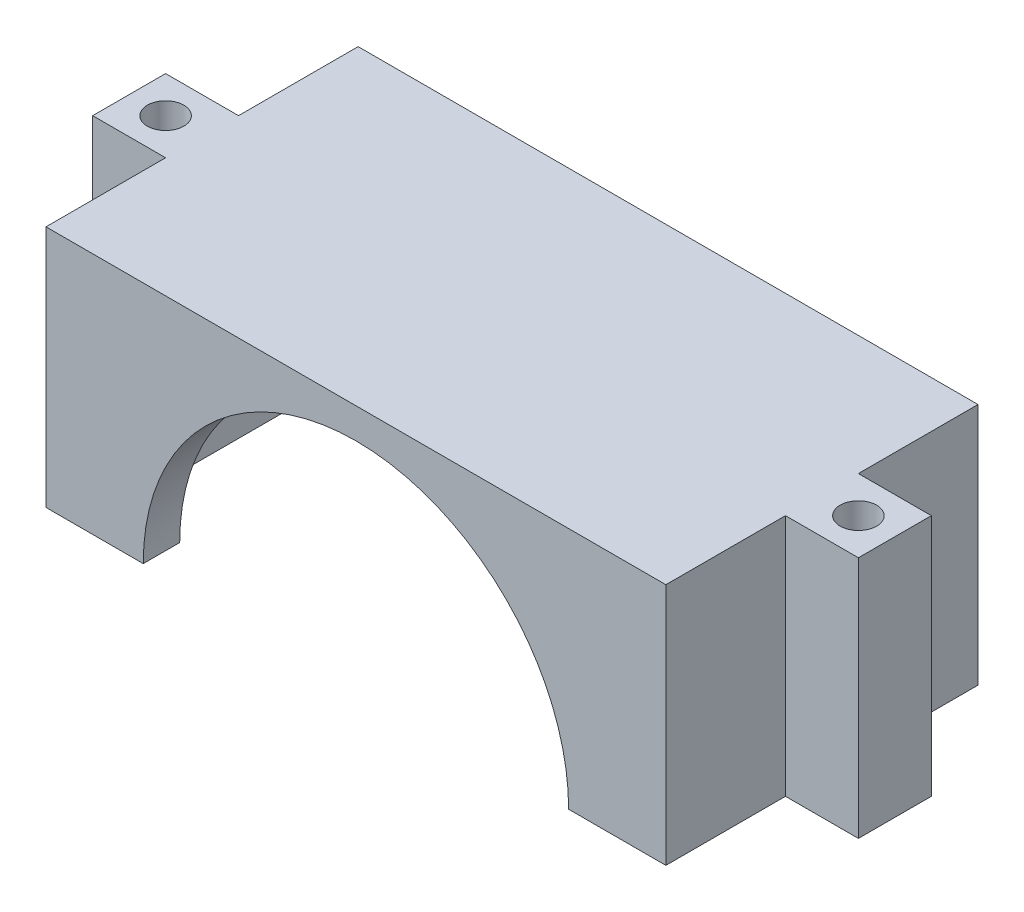
from build123d import *

# Parameters (mm, degrees)
SKETCH1_W           = 51
SKETCH1_H           = 25.68
BOSS_EXTRUDE1_DEPTH = 20
SKETCH3_W           = 45
SKETCH3_H           = 19.68
CUT_EXTRUDE1_DEPTH  = 17.5
CUT_EXTRUDE2_DEPTH  = 3
SKETCH5_W           = 10
SKETCH5_H           = 6
CUT_EXTRUDE3_DEPTH  = 3
SKETCH6_W           = 6
SKETCH6_H           = 6
SKETCH6_R           = 1.5
BOSS_EXTRUDE2_DEPTH = 20


with BuildPart() as part:
    # Sketch1 → Boss-Extrude1 (new body)
    with BuildSketch(Plane(origin=(0, 0, 0), x_dir=(1, 0, 0), z_dir=(0, 1, 0))):
        Rectangle(SKETCH1_W, SKETCH1_H)
    extrude(amount=BOSS_EXTRUDE1_DEPTH)

    # Sketch3 → Cut-Extrude1 (cut)
    with BuildSketch(Plane.XZ):
        Rectangle(SKETCH3_W, SKETCH3_H)
    extrude(amount=-CUT_EXTRUDE1_DEPTH, mode=Mode.SUBTRACT)

    # Sketch4 → Cut-Extrude2 (cut)
    with BuildSketch(Plane.XY.offset(12.84)):
        with BuildLine():
            Line((-17.5, 0), (17.5, 0))
            ThreePointArc((17.5, 0), (0, 17.5), (-17.5, 0))
        make_face()
    extrude(amount=-CUT_EXTRUDE2_DEPTH, mode=Mode.SUBTRACT)

    # Sketch5 → Cut-Extrude3 (cut)
    with BuildSketch(Plane(origin=(0, 0, -12.84), x_dir=(-1, 0, 0), z_dir=(0, 0, -1))):
        with Locations((-17, 3)):
            Rectangle(SKETCH5_W, SKETCH5_H)
    extrude(amount=-CUT_EXTRUDE3_DEPTH, mode=Mode.SUBTRACT)

    # Sketch6 → Boss-Extrude2 (add)
    with BuildSketch(Plane.XZ):
        with Locations((28.5, 0)):
            Rectangle(SKETCH6_W, SKETCH6_H)
        with Locations((28.5, 0)):
            Circle(SKETCH6_R, mode=Mode.SUBTRACT)
        with Locations((-28.5, 0)):
            Rectangle(SKETCH6_W, SKETCH6_H)
        with Locations((-28.5, 0)):
            Circle(SKETCH6_R, mode=Mode.SUBTRACT)
    extrude(amount=-BOSS_EXTRUDE2_DEPTH)


solid = part.part
